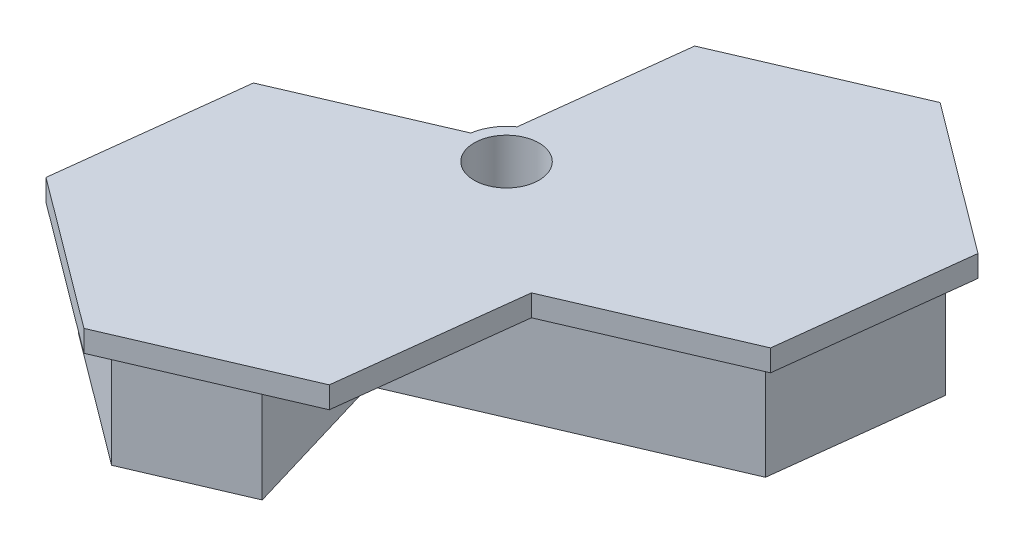
from build123d import *

# Parameters (mm, degrees)
SKETCH1_R           = 1.5
BOSS_EXTRUDE1_DEPTH = 6
BOSS_EXTRUDE2_DEPTH = 1


with BuildPart() as part:
    # Sketch1 → Boss-Extrude1 (new body)
    with BuildSketch(Plane(origin=(0, 0, 0), x_dir=(1, 0, 0), z_dir=(0, 1, 0))):
        with BuildLine():
            ThreePointArc((2.346955398, 0.261158526), (0.766582759, -0.648437779), (0.581159215, -2.462428195))
            Line((0.581159215, -2.462428195), (-5.646281291, -5.138082195))
            Line((-5.646281291, -5.138082195), (-6.527676066, -12.586111683))
            Line((-6.527676066, -12.586111683), (-0.518190709, -17.073436693))
            Line((-0.518190709, -17.073436693), (4.364038924, -14.975759929))
            Line((4.364038924, -14.975759929), (2.260805866, -7.930513525))
            Line((2.260805866, -7.930513525), (15.112004176, -2.408925622))
            Line((15.112004176, -2.408925622), (15.993398951, 5.039103866))
            Line((15.993398951, 5.039103866), (9.983913594, 9.526428876))
            Line((9.983913594, 9.526428876), (3.093033462, 6.565724398))
            Line((3.093033462, 6.565724398), (2.346955398, 0.261158526))
        make_face()
        with Locations((2.445675843, -1.738841474)):
            Circle(SKETCH1_R, mode=Mode.SUBTRACT)
    extrude(amount=BOSS_EXTRUDE1_DEPTH)

    # Sketch2 → Boss-Extrude2 (add)
    with BuildSketch(Plane(origin=(0, 6, 0), x_dir=(1, 0, 0), z_dir=(0, 1, 0))):
        with BuildLine():
            Line((0.469627416, -1.421953369), (-6.571502088, -4.447213314))
            Line((-6.571502088, -4.447213314), (-7.588596466, -13.041941957))
            Line((-7.588596466, -13.041941957), (-0.653890312, -18.220135847))
            Line((-0.653890312, -18.220135847), (7.29791022, -14.803601096))
            Line((7.29791022, -14.803601096), (8.288969653, -6.428874937))
            Line((8.288969653, -6.428874937), (16.037224973, -3.099794503))
            Line((16.037224973, -3.099794503), (17.054319351, 5.494934139))
            Line((17.054319351, 5.494934139), (10.119613197, 10.67312803))
            Line((10.119613197, 10.67312803), (2.167812665, 7.256593278))
            Line((2.167812665, 7.256593278), (1.297445688, -0.098248268))
            ThreePointArc((1.297445688, -0.098248268), (1.796782906, 0.15567759), (2.346955398, 0.261158526))
            Line((2.346955398, 0.261158526), (3.093033462, 6.565724398))
            Line((3.093033462, 6.565724398), (9.983913594, 9.526428876))
            Line((9.983913594, 9.526428876), (15.993398951, 5.039103866))
            Line((15.993398951, 5.039103866), (15.112004176, -2.408925622))
            Line((15.112004176, -2.408925622), (2.260805866, -7.930513525))
            Line((2.260805866, -7.930513525), (4.364038924, -14.975759929))
            Line((4.364038924, -14.975759929), (-0.518190709, -17.073436693))
            Line((-0.518190709, -17.073436693), (-6.527676066, -12.586111683))
            Line((-6.527676066, -12.586111683), (-5.646281291, -5.138082195))
            Line((-5.646281291, -5.138082195), (0.581159215, -2.462428195))
            ThreePointArc((0.581159215, -2.462428195), (0.456138011, -1.949614478), (0.469627416, -1.421953369))
        make_face()
    extrude(amount=-BOSS_EXTRUDE2_DEPTH)


solid = part.part
